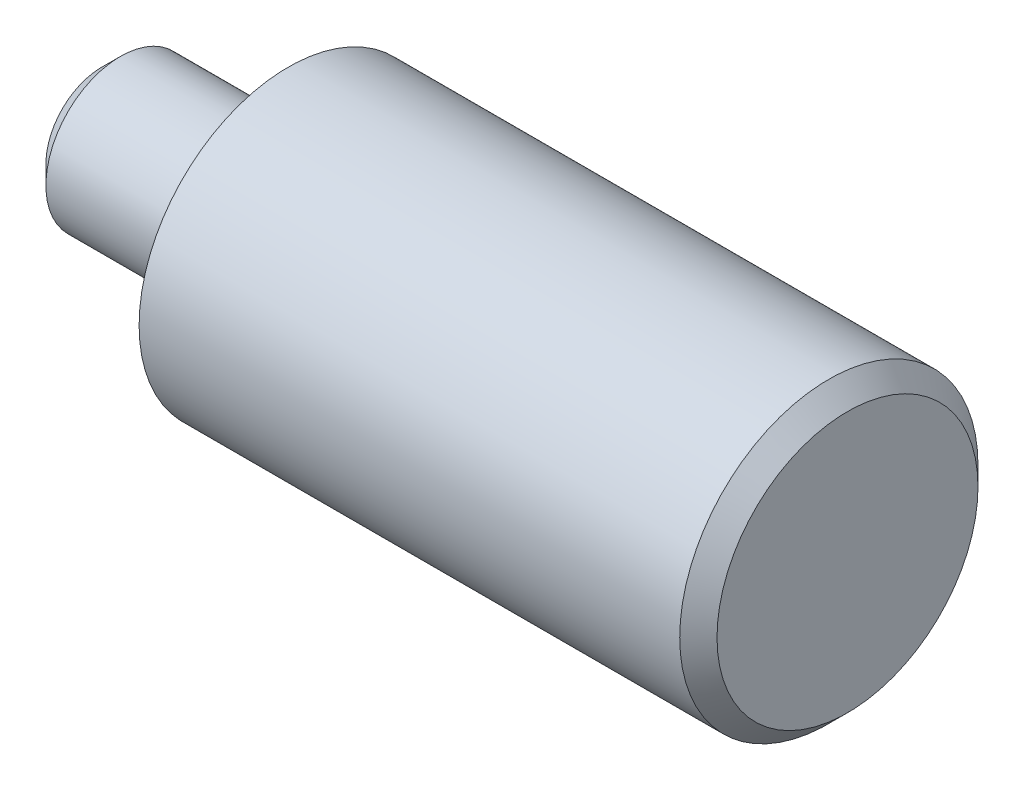
from build123d import *

# Parameters (mm, degrees)
CHAMFER1_SIZE = 1
SKETCH2_W     = 1
SKETCH2_H     = 1


with BuildPart() as part:
    # Sketch1 → Revolve1 (revolve)
    with BuildSketch(Plane.XY):
        Polygon((0, 0), (0, 8), (-30, 8), (-30, 4), (-40, 4), (-40, 0), align=None)
    revolve(axis=Axis((-114.784060064, 0, 0), (1, 0, 0)))

    # Chamfer1
    chamfer1_edges = [part.edges().sort_by_distance(p)[0] for p in [
        (-40, -4, 0),
        (0, -8, 0),
    ]]
    chamfer(chamfer1_edges, length=CHAMFER1_SIZE)

    # Sketch2 → Cut-Revolve1 (revolve, cut)
    with BuildSketch(Plane.XY):
        with Locations((-30.5, 3.5)):
            Rectangle(SKETCH2_W, SKETCH2_H)
    revolve(axis=Axis((0, 0, 0), (-1, 0, 0)), mode=Mode.SUBTRACT)


solid = part.part
